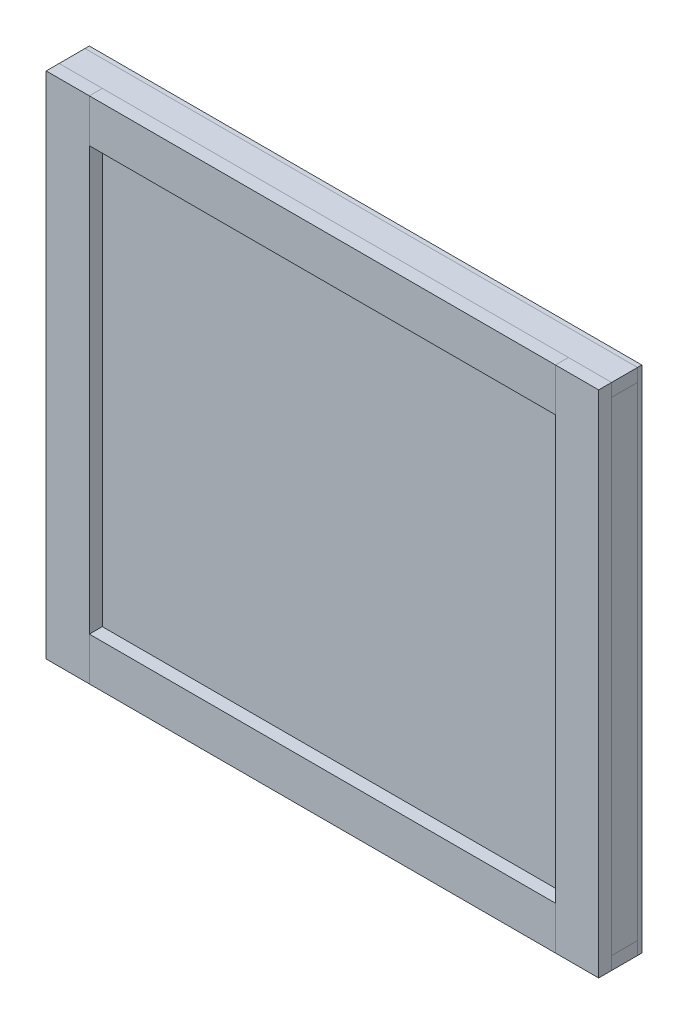
from build123d import *

# Parameters (mm, degrees)
SKETCH1_W             = 812.8
SKETCH1_H             = 749.3
BOSS_EXTRUDE1_DEPTH   = 6.35
SKETCH2_W             = 812.8
SKETCH2_H             = 19.05
BOSS_EXTRUDE2_DEPTH   = 38.1
BOSS_EXTRUDE2_2_DEPTH = 38.1
SKETCH2_3_W           = 19.05
SKETCH2_3_H           = 711.2
BOSS_EXTRUDE3_DEPTH   = 38.1
BOSS_EXTRUDE3_2_DEPTH = 38.1
SKETCH3_W             = 63.5
SKETCH3_H             = 749.3
BOSS_EXTRUDE4_DEPTH   = 19.05
BOSS_EXTRUDE4_2_DEPTH = 19.05
SKETCH3_3_W           = 685.8
SKETCH3_3_H           = 63.5
BOSS_EXTRUDE5_DEPTH   = 19.05
BOSS_EXTRUDE5_2_DEPTH = 19.05


with BuildPart() as part:
    # Sketch1 → Boss-Extrude1 (new body)
    with BuildSketch(Plane.XY):
        Rectangle(SKETCH1_W, SKETCH1_H)
    extrude(amount=BOSS_EXTRUDE1_DEPTH)


with BuildPart() as body_2:
    # Sketch2 → Boss-Extrude2 (new body)
    with BuildSketch(Plane.XY.offset(6.35)):
        with Locations((0, 365.125)):
            Rectangle(SKETCH2_W, SKETCH2_H)
    extrude(amount=BOSS_EXTRUDE2_DEPTH)


with BuildPart() as body_3:
    # Sketch2 → Boss-Extrude2 2 (new body)
    with BuildSketch(Plane.XY.offset(6.35)):
        with Locations((0, -365.125)):
            Rectangle(SKETCH2_W, SKETCH2_H)
    extrude(amount=BOSS_EXTRUDE2_2_DEPTH)


with BuildPart() as body_4:
    # Sketch2_3 → Boss-Extrude3 (new body)
    with BuildSketch(Plane.XY.offset(6.35)):
        with Locations((-396.875, 0)):
            Rectangle(SKETCH2_3_W, SKETCH2_3_H)
    extrude(amount=BOSS_EXTRUDE3_DEPTH)


with BuildPart() as body_5:
    # Sketch2_3 → Boss-Extrude3 2 (new body)
    with BuildSketch(Plane.XY.offset(6.35)):
        with Locations((396.875, 0)):
            Rectangle(SKETCH2_3_W, SKETCH2_3_H)
    extrude(amount=BOSS_EXTRUDE3_2_DEPTH)


with BuildPart() as body_6:
    # Sketch3 → Boss-Extrude4 (new body)
    with BuildSketch(Plane.XY.offset(44.45)):
        with Locations((-374.65, 0)):
            Rectangle(SKETCH3_W, SKETCH3_H)
    extrude(amount=BOSS_EXTRUDE4_DEPTH)


with BuildPart() as body_7:
    # Sketch3 → Boss-Extrude4 2 (new body)
    with BuildSketch(Plane.XY.offset(44.45)):
        with Locations((374.65, 0)):
            Rectangle(SKETCH3_W, SKETCH3_H)
    extrude(amount=BOSS_EXTRUDE4_2_DEPTH)


with BuildPart() as body_8:
    # Sketch3_3 → Boss-Extrude5 (new body)
    with BuildSketch(Plane.XY.offset(44.45)):
        with Locations((0, 342.9)):
            Rectangle(SKETCH3_3_W, SKETCH3_3_H)
    extrude(amount=BOSS_EXTRUDE5_DEPTH)


with BuildPart() as body_9:
    # Sketch3_3 → Boss-Extrude5 2 (new body)
    with BuildSketch(Plane.XY.offset(44.45)):
        with Locations((0, -342.9)):
            Rectangle(SKETCH3_3_W, SKETCH3_3_H)
    extrude(amount=BOSS_EXTRUDE5_2_DEPTH)


solid = Compound([part.part, body_2.part, body_3.part, body_4.part, body_5.part, body_6.part, body_7.part, body_8.part, body_9.part])
